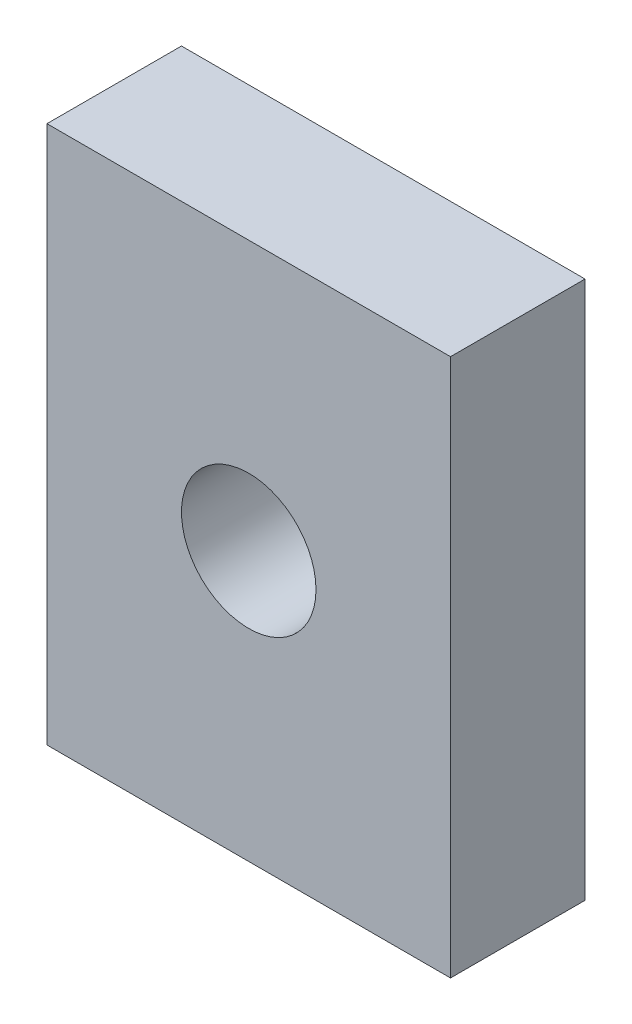
from build123d import *

# Parameters (mm, degrees)
ESBO_O1_W                = 15
ESBO_O1_H                = 20
ESBO_O1_R                = 2.5
RESSALTO_EXTRUS_O1_DEPTH = 5


with BuildPart() as part:
    # Esboço1 → Ressalto-extrusão1 (new body)
    with BuildSketch(Plane.XY):
        Rectangle(ESBO_O1_W, ESBO_O1_H)
        Circle(ESBO_O1_R, mode=Mode.SUBTRACT)
    extrude(amount=RESSALTO_EXTRUS_O1_DEPTH)


solid = part.part
